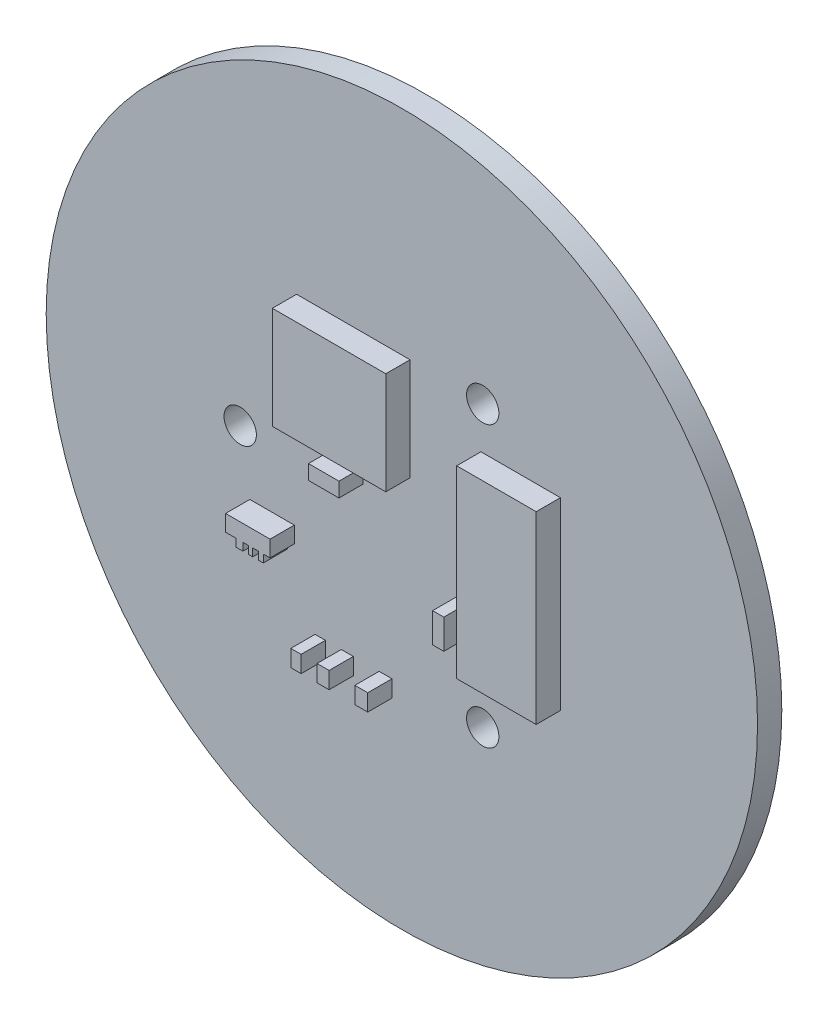
from build123d import *

# Parameters (mm, degrees)
SKETCH_1_R          = 22
EXTRUDE_1_DEPTH     = 1.5
SKETCH_2_W          = 4
SKETCH_2_H          = 5
EXTRUDE_2_DEPTH     = 1.8
SKETCH_3_R          = 1
CUT_EXTRUDE_1_DEPTH = 1.8
SKETCH_4_W          = 7.015976939
SKETCH_4_H          = 6.325009514
SKETCH_4_W_2        = 4.916498991
SKETCH_4_H_2        = 11.400962527
SKETCH_4_W_3        = 1.886872586
SKETCH_4_H_3        = 0.903572787
SKETCH_4_W_4        = 0.637816086
SKETCH_4_H_4        = 1.036451139
SKETCH_4_W_5        = 0.744118766
SKETCH_4_W_6        = 0.797270107
SKETCH_4_W_7        = 0.690967426
SKETCH_4_H_5        = 1.833721246
EXTRUDE_3_DEPTH     = 1.5


with BuildPart() as part:
    # 草图1 → 凸台-拉伸1 (new body)
    with BuildSketch(Plane.XY):
        Circle(SKETCH_1_R)
    extrude(amount=EXTRUDE_1_DEPTH)

    # 草图2 → 凸台-拉伸2 (add)
    with BuildSketch(Plane(origin=(0, 0, 0), x_dir=(-1, 0, 0), z_dir=(0, 0, -1))):
        Rectangle(SKETCH_2_W, SKETCH_2_H)
    extrude(amount=EXTRUDE_2_DEPTH)

    # 草图3 → 切除-拉伸1 (cut)
    with BuildSketch(Plane(origin=(0, 0, 0), x_dir=(-1, 0, 0), z_dir=(0, 0, -1))):
        with Locations((10, 0)):
            Circle(SKETCH_3_R)
        with Locations((-5, 8.660254038)):
            Circle(SKETCH_3_R)
        with Locations((-5, -8.660254038)):
            Circle(SKETCH_3_R)
    extrude(amount=-CUT_EXTRUDE_1_DEPTH, mode=Mode.SUBTRACT)

    # 草图4 → 凸台-拉伸3 (add)
    with BuildSketch(Plane.XY.offset(1.5)):
        Polygon((-8.105579419, -3.654154656), (-6.654300112, -3.654154656), (-6.654300112, -4.661389837), (-7.070508219, -4.661389837), (-7.070508219, -5.140659778), (-7.379939766, -5.140659778), (-7.379939766, -4.661389837), (-7.726351297, -4.661389837), (-7.726351297, -5.140659778), (-7.991211002, -5.140659778), (-7.991211002, -4.661389837), (-8.331744908, -4.661389837), (-8.331744908, -5.140659778), (-8.747953015, -5.140659778), (-8.747953015, -4.661389837), (-9.403796093, -4.661389837), (-9.403796093, -3.654154656), align=None)
        with Locations((-3.003050736, 5.620754253)):
            Rectangle(SKETCH_4_W, SKETCH_4_H)
        with Locations((7.348172818, 0.345483713)):
            Rectangle(SKETCH_4_W_2, SKETCH_4_H_2)
        with Locations((-3.335246613, 1.129465985)):
            Rectangle(SKETCH_4_W_3, SKETCH_4_H_3)
        with Locations((-5.049377343, -9.38121159)):
            Rectangle(SKETCH_4_W_4, SKETCH_4_H_4)
        with Locations((-3.375110119, -9.38121159)):
            Rectangle(SKETCH_4_W_5, SKETCH_4_H_4)
        with Locations((-1.009875468, -9.38121159)):
            Rectangle(SKETCH_4_W_6, SKETCH_4_H_4)
        with Locations((3.747169502, -3.375110119)):
            Rectangle(SKETCH_4_W_7, SKETCH_4_H_5)
    extrude(amount=EXTRUDE_3_DEPTH)


solid = part.part
